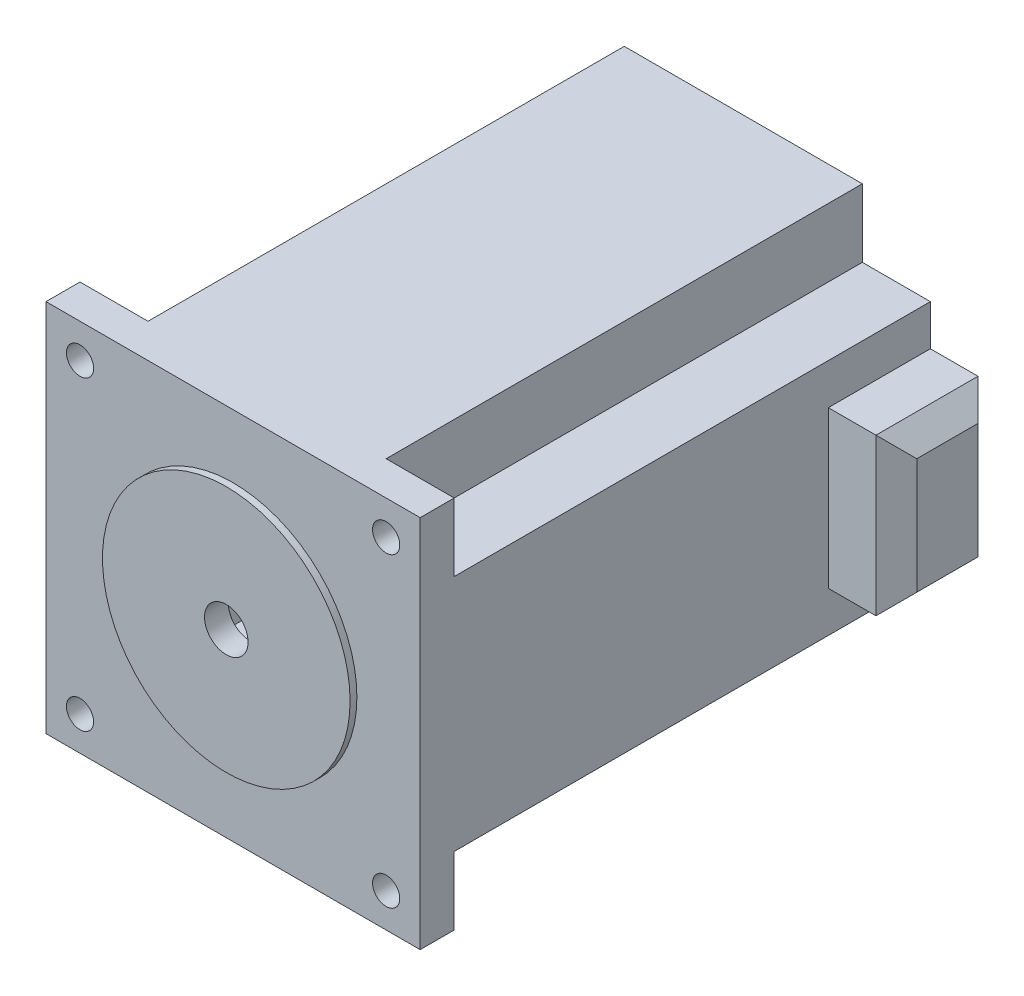
from build123d import *

# Parameters (mm, degrees)
SKETCH2_W           = 55
SKETCH2_H           = 55
SKETCH2_W_2         = 30
SKETCH2_H_2         = 30
BOSS_EXTRUDE1_DEPTH = 35
SKETCH3_W           = 55
SKETCH3_H           = 55
SKETCH3_R           = 3.2
BOSS_EXTRUDE2_DEPTH = 2.5
SKETCH4_W           = 55
SKETCH4_H           = 55
SKETCH4_R           = 3.2
BOSS_EXTRUDE3_DEPTH = 2.5
SKETCH6_R           = 18.2
SKETCH6_R_2         = 3.2
BOSS_EXTRUDE4_DEPTH = 1
SKETCH7_W           = 15
SKETCH7_H           = 23
BOSS_EXTRUDE5_DEPTH = 10
CHAMFER1_SIZE       = 3
SKETCH8_W           = 10
SKETCH8_H           = 10
CUT_EXTRUDE1_DEPTH  = 70
SKETCH9_R           = 2
CUT_EXTRUDE2_DEPTH  = 5


with BuildPart() as part:
    # Sketch2 → Boss-Extrude1 (new body, symmetric)
    with BuildSketch(Plane.XY):
        Rectangle(SKETCH2_W, SKETCH2_H)
        Rectangle(SKETCH2_W_2, SKETCH2_H_2, mode=Mode.SUBTRACT)
    extrude(amount=BOSS_EXTRUDE1_DEPTH, both=True)

    # Sketch3 → Boss-Extrude2 (add)
    with BuildSketch(Plane.XY.offset(35)):
        Rectangle(SKETCH3_W, SKETCH3_H)
        Circle(SKETCH3_R, mode=Mode.SUBTRACT)
    extrude(amount=BOSS_EXTRUDE2_DEPTH)

    # Sketch4 → Boss-Extrude3 (add)
    with BuildSketch(Plane(origin=(0, 0, -35), x_dir=(-1, 0, 0), z_dir=(0, 0, -1))):
        Rectangle(SKETCH4_W, SKETCH4_H)
        Circle(SKETCH4_R, mode=Mode.SUBTRACT)
    extrude(amount=BOSS_EXTRUDE3_DEPTH)

    # Sketch6 → Boss-Extrude4 (add)
    with BuildSketch(Plane.XY.offset(37.5)):
        Circle(SKETCH6_R)
        Circle(SKETCH6_R_2, mode=Mode.SUBTRACT)
    extrude(amount=BOSS_EXTRUDE4_DEPTH)

    # Sketch7 → Boss-Extrude5 (add)
    with BuildSketch(Plane(origin=(27.5, 0, 0), x_dir=(0, 0, -1), z_dir=(1, 0, 0))):
        with Locations((30, 0)):
            Rectangle(SKETCH7_W, SKETCH7_H)
    extrude(amount=BOSS_EXTRUDE5_DEPTH)

    # Chamfer1
    chamfer1_edges = [part.edges().sort_by_distance(p)[0] for p in [
        (37.5, 0, -22.5),
        (37.5, -11.5, -30),
        (37.5, 0, -37.5),
        (37.5, 11.5, -30),
    ]]
    chamfer(chamfer1_edges, length=CHAMFER1_SIZE)

    # Sketch8 → Cut-Extrude1 (cut)
    with BuildSketch(Plane(origin=(0, 0, -37.5), x_dir=(-1, 0, 0), z_dir=(0, 0, -1))):
        with Locations((-22.5, 22.5)):
            Rectangle(SKETCH8_W, SKETCH8_H)
        with Locations((22.5, 22.5)):
            Rectangle(SKETCH8_W, SKETCH8_H)
        with Locations((-22.5, -22.5)):
            Rectangle(SKETCH8_W, SKETCH8_H)
        with Locations((22.5, -22.5)):
            Rectangle(SKETCH8_W, SKETCH8_H)
    extrude(amount=-CUT_EXTRUDE1_DEPTH, mode=Mode.SUBTRACT)

    # Sketch9 → Cut-Extrude2 (cut)
    with BuildSketch(Plane.XY.offset(37.5)):
        with Locations((-22.5, 22.5)):
            Circle(SKETCH9_R)
        with Locations((22.5, 22.5)):
            Circle(SKETCH9_R)
        with Locations((-22.5, -22.5)):
            Circle(SKETCH9_R)
        with Locations((22.5, -22.5)):
            Circle(SKETCH9_R)
    extrude(amount=-CUT_EXTRUDE2_DEPTH, mode=Mode.SUBTRACT)


solid = part.part
